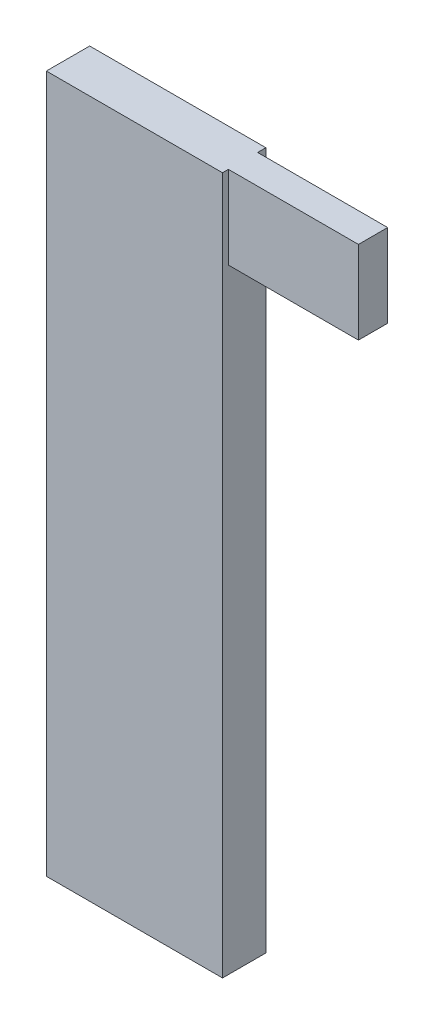
from build123d import *

# Parameters (mm, degrees)
SKETCH1_W           = 5.162383308
SKETCH1_H           = 20.435052184
BOSS_EXTRUDE1_DEPTH = 1.27
SKETCH2_W           = 0.838933851
SKETCH2_H           = 3.882140463
CUT_EXTRUDE1_DEPTH  = 3.81
SKETCH3_W           = 0.856262928
SKETCH3_H           = 2.429514696
BOSS_EXTRUDE2_DEPTH = 3.81


with BuildPart() as part:
    # Sketch1 → Boss-Extrude1 (new body)
    with BuildSketch(Plane.XY):
        with Locations((-34.98361032, 7.835499756)):
            Rectangle(SKETCH1_W, SKETCH1_H)
    extrude(amount=BOSS_EXTRUDE1_DEPTH)

    # Sketch2 → Cut-Extrude1 (cut)
    with BuildSketch(Plane.ZY.offset(37.564801974)):
        with Locations((0.611191145, 14.932897959)):
            Rectangle(SKETCH2_W, SKETCH2_H)
    extrude(amount=-CUT_EXTRUDE1_DEPTH, mode=Mode.SUBTRACT)

    # Sketch3 → Boss-Extrude2 (add)
    with BuildSketch(Plane(origin=(-32.402418666, 0, 0), x_dir=(0, 0, -1), z_dir=(1, 0, 0))):
        with Locations((-0.669030721, 16.8382685)):
            Rectangle(SKETCH3_W, SKETCH3_H)
    extrude(amount=BOSS_EXTRUDE2_DEPTH)


solid = part.part
